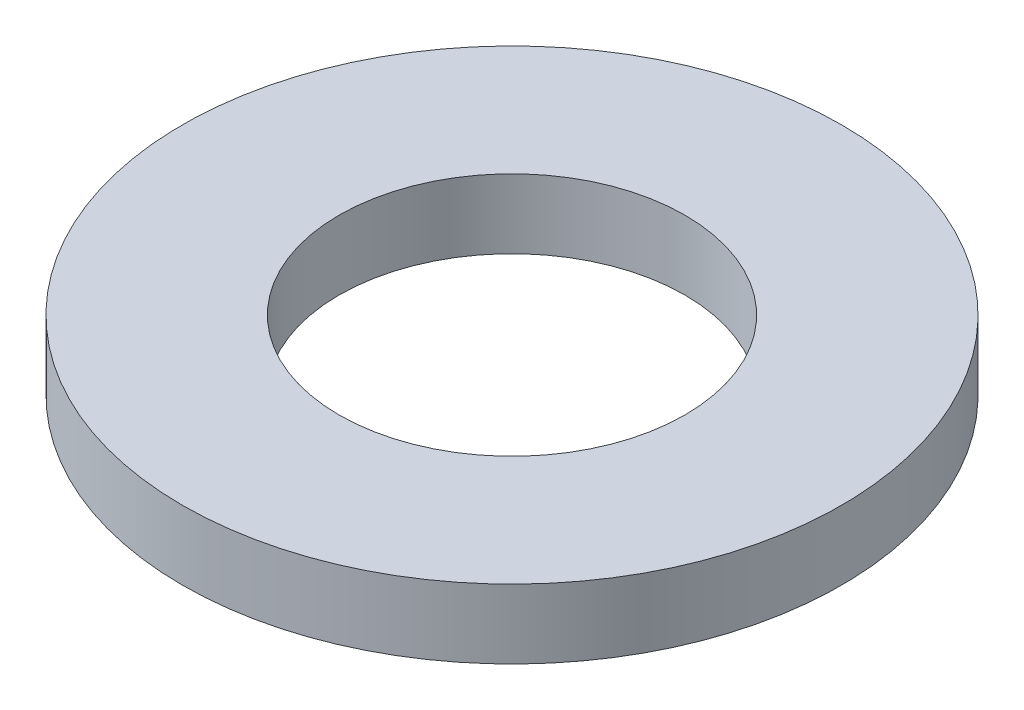
from build123d import *

# Parameters (mm, degrees)
SKETCH1_R           = 4.7625
SKETCH1_R_2         = 2.499999953
BOSS_EXTRUDE1_DEPTH = 1


with BuildPart() as part:
    # Sketch1 → Boss-Extrude1 (new body)
    with BuildSketch(Plane(origin=(0, 0, 0), x_dir=(1, 0, 0), z_dir=(0, 1, 0))):
        Circle(SKETCH1_R)
        Circle(SKETCH1_R_2, mode=Mode.SUBTRACT)
    extrude(amount=BOSS_EXTRUDE1_DEPTH)


solid = part.part
